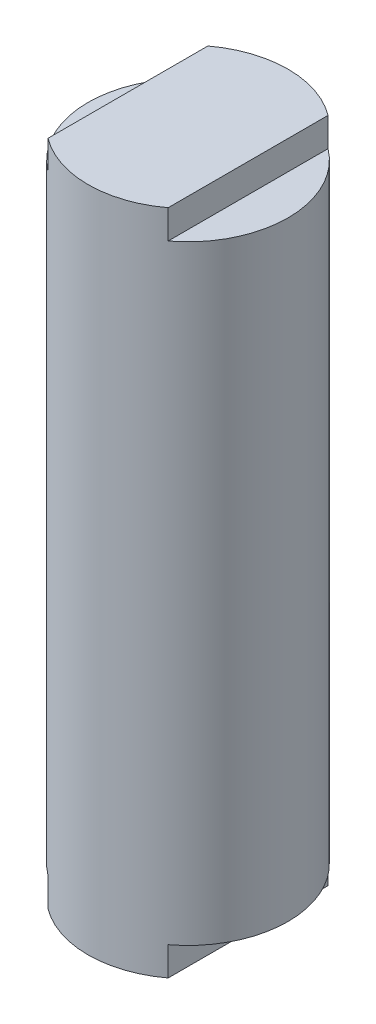
from build123d import *

# Parameters (mm, degrees)
SKETCH2_R               = 26.415
EXTRUDE1_DEPTH          = 88.10625
SKETCH3_W               = 10.541
SKETCH3_H               = 7.62
EXTRUDE2_DEPTH          = 27.415
MIRROR2_COPY_1_SKETCH_W = 10.541
MIRROR2_COPY_1_SKETCH_H = 7.62
MIRROR2_COPY_1_DEPTH    = 27.415


with BuildPart() as part:
    # Sketch2 → Extrude1 (new body, symmetric)
    with BuildSketch(Plane(origin=(0, 0, 0), x_dir=(1, 0, 0), z_dir=(0, 1, 0))):
        Circle(SKETCH2_R)
    extrude(amount=EXTRUDE1_DEPTH, both=True)

    # Sketch3 → Extrude2 (cut, symmetric)
    with BuildSketch(Plane.XY):
        with Locations((21.1445, 84.29625)):
            Rectangle(SKETCH3_W, SKETCH3_H)
    extrude2 = extrude(amount=EXTRUDE2_DEPTH, both=True, mode=Mode.SUBTRACT)

    # Mirror1: Extrude2 across plane
    add(extrude2.mirror(Plane(origin=(0, 0, 0), x_dir=(0, 0, 1), z_dir=(1, 0, 0))), mode=Mode.SUBTRACT)

    # Mirror2: Extrude2 across plane
    add(extrude2.mirror(Plane.ZX), mode=Mode.SUBTRACT)

    # Mirror2 copy 1 sketch → Mirror2 copy 1 (cut, symmetric)
    with BuildSketch(Plane(origin=(0, 0, 0), x_dir=(-1, 0, 0), z_dir=(0, 0, 1))):
        with Locations((21.1445, 84.29625)):
            Rectangle(MIRROR2_COPY_1_SKETCH_W, MIRROR2_COPY_1_SKETCH_H)
    extrude(amount=MIRROR2_COPY_1_DEPTH, both=True, mode=Mode.SUBTRACT)


solid = part.part
